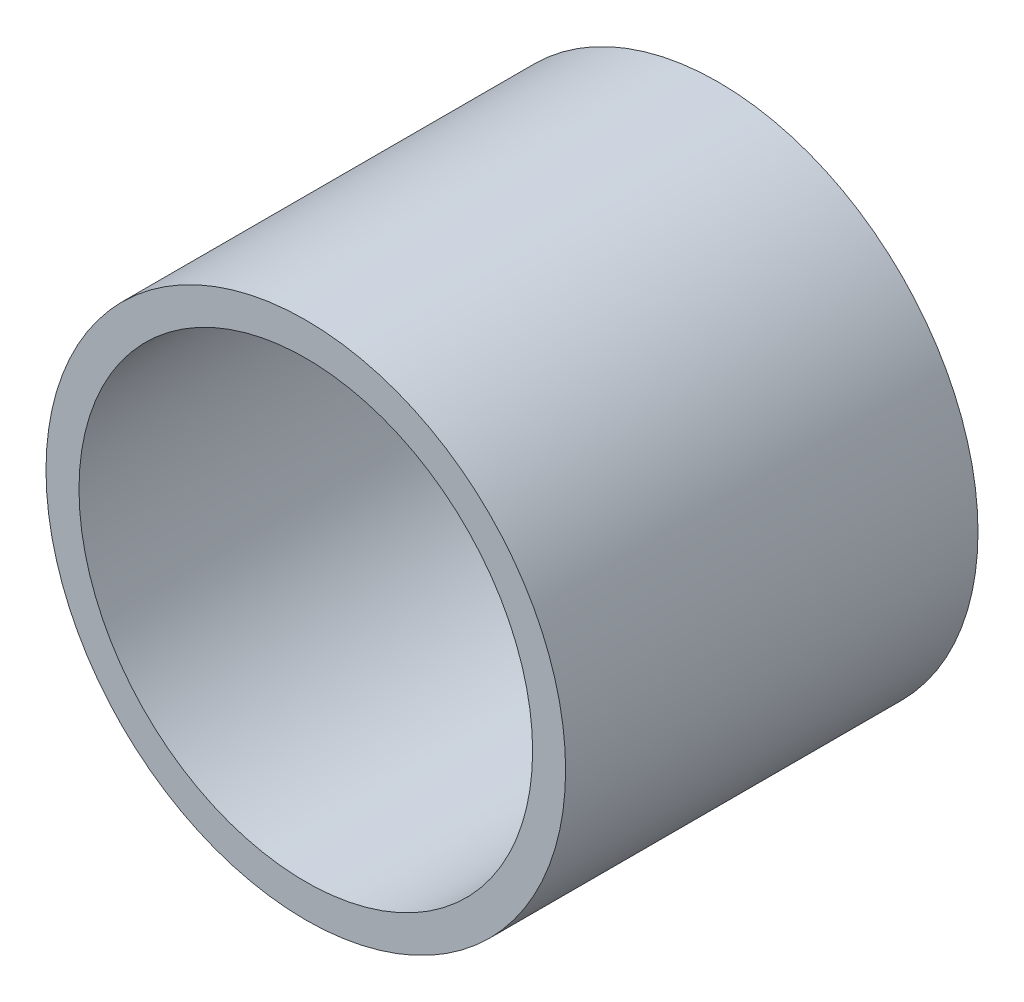
from build123d import *

# Parameters (mm, degrees)
SKETCH1_R           = 31.5
SKETCH1_R_2         = 27.5
BOSS_EXTRUDE1_DEPTH = 50


with BuildPart() as part:
    # Sketch1 → Boss-Extrude1 (new body)
    with BuildSketch(Plane.XY):
        Circle(SKETCH1_R)
        Circle(SKETCH1_R_2, mode=Mode.SUBTRACT)
    extrude(amount=BOSS_EXTRUDE1_DEPTH)


solid = part.part
